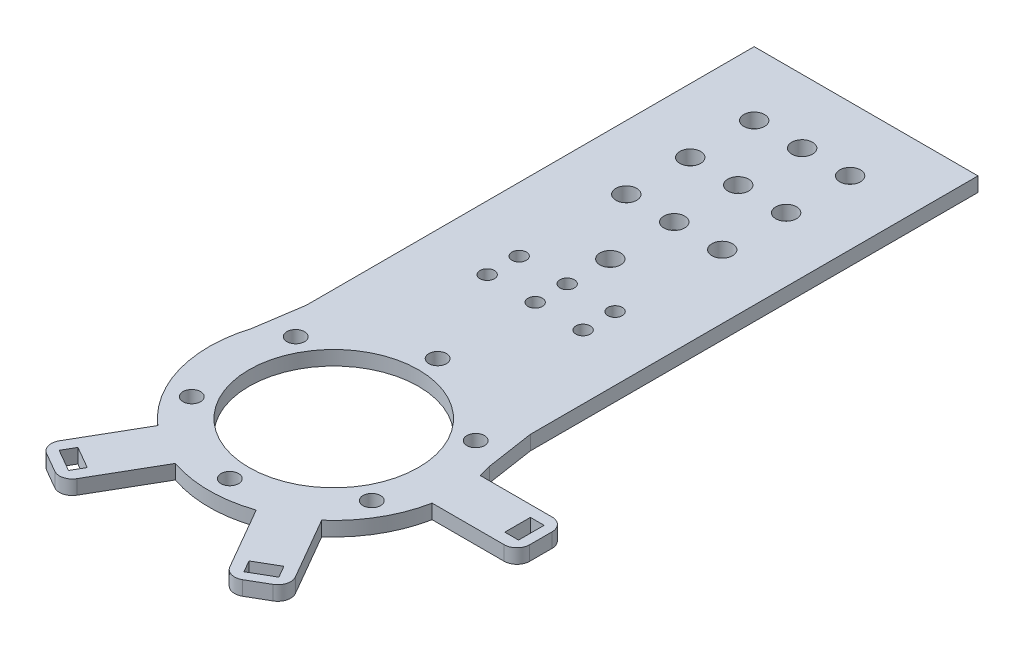
from build123d import *

# Parameters (mm, degrees)
SKETCH1_R                = 39
SKETCH1_R_2              = 26.5
BOSS_EXTRUDE1_DEPTH      = 2.25
SKETCH3_W                = 50
SKETCH3_H                = 51.5
BOSS_EXTRUDE2_DEPTH      = 2.25
BOSS_EXTRUDE4_DEPTH      = 2.25
SKETCH2_R                = 2.75
CUT_EXTRUDE1_DEPTH       = 3.25
CIRPATTERN1_COUNT        = 6
CUT_EXTRUDE2_START       = -5.5
SKETCH5_R                = 2.25
CUT_EXTRUDE2_DEPTH       = 6.5
LPATTERN1_COUNT          = 2
LPATTERN1_PITCH          = 15
LPATTERN1_COUNT_DIR2     = 2
LPATTERN1_PITCH_DIR2     = 10
LPATTERN2_COUNT          = 2
LPATTERN2_PITCH          = 15
LPATTERN2_COUNT_DIR2     = 2
LPATTERN2_PITCH_DIR2     = 10
CUT_EXTRUDE3_START       = -5.5
SKETCH7_R                = 3.25
CUT_EXTRUDE3_DEPTH       = 6.5
LPATTERN3_COUNT          = 3
LPATTERN3_PITCH          = 20
SKETCH8_R                = 3.25
CUT_EXTRUDE4_DEPTH       = 10
LPATTERN4_COUNT          = 4
LPATTERN4_PITCH          = 20
SKETCH9_W                = 27
SKETCH9_H                = 15
SKETCH9_W_2              = 4.3
SKETCH9_H_2              = 8
BOSS_EXTRUDE5_DEPTH      = 2.25
FILLET1_R                = 4
CIRPATTERN2_COUNT        = 3
CIRPATTERN2_ANGLE        = 120
FILLET1_OF_CIRPATTERN2_R = 4


with BuildPart() as part:
    # Sketch1 → Boss-Extrude1 (new body, symmetric)
    with BuildSketch(Plane(origin=(0, 0, 0), x_dir=(1, 0, 0), z_dir=(0, 1, 0))):
        Circle(SKETCH1_R)
        Circle(SKETCH1_R_2, mode=Mode.SUBTRACT)
    extrude(amount=BOSS_EXTRUDE1_DEPTH, both=True)

    # Sketch3 → Boss-Extrude2 (add, symmetric)
    with BuildSketch(Plane(origin=(0, 0, 0), x_dir=(1, 0, 0), z_dir=(0, 1, 0))):
        with Locations((0, 52.25)):
            Rectangle(SKETCH3_W, SKETCH3_H)
    extrude(amount=BOSS_EXTRUDE2_DEPTH, both=True)

    # Sketch6 → Boss-Extrude4 (add, symmetric)
    with BuildSketch(Plane(origin=(0, 0, 0), x_dir=(1, 0, 0), z_dir=(0, 1, 0))):
        Polygon((-35, 166.5), (-35, 26.5), (-39, 0), (-14.981514186, 26.5), (16.520833333, 26.5), (39, 0), (35, 26.5), (35, 166.5), align=None)
    extrude(amount=BOSS_EXTRUDE4_DEPTH, both=True)

    # Sketch2 → Cut-Extrude1 (cut, symmetric)
    with BuildSketch(Plane(origin=(0, 0, 0), x_dir=(1, 0, 0), z_dir=(0, 1, 0))):
        with Locations((0, 32.5)):
            Circle(SKETCH2_R)
    cut_extrude1 = extrude(amount=CUT_EXTRUDE1_DEPTH, both=True, mode=Mode.SUBTRACT)

    # CirPattern1: Cut-Extrude1 ×6 about axis
    cirpattern1_axis = Axis((0, 0, 0), (0, 1, 0))
    for i in range(1, CIRPATTERN1_COUNT):
        add(cut_extrude1.rotate(cirpattern1_axis, i * 360 / CIRPATTERN1_COUNT), mode=Mode.SUBTRACT)

    # Sketch5 → Cut-Extrude2 (cut)
    with BuildSketch(Plane(origin=(0, 2.25, 0), x_dir=(1, 0, 0), z_dir=(0, 1, 0)).offset(CUT_EXTRUDE2_START)):
        with Locations((0, 73)):
            Circle(SKETCH5_R)
    cut_extrude2 = extrude(amount=CUT_EXTRUDE2_DEPTH, mode=Mode.SUBTRACT)

    # LPattern1: Cut-Extrude2 2 × 2
    with Locations(*[(i * LPATTERN1_PITCH, 0, j * LPATTERN1_PITCH_DIR2) for i in range(LPATTERN1_COUNT) for j in range(LPATTERN1_COUNT_DIR2) if (i, j) != (0, 0)]):
        add(cut_extrude2, mode=Mode.SUBTRACT)

    # LPattern2: Cut-Extrude2 2 × 2
    with Locations(*[(-i * LPATTERN2_PITCH, 0, j * LPATTERN2_PITCH_DIR2) for i in range(LPATTERN2_COUNT) for j in range(LPATTERN2_COUNT_DIR2) if (i, j) != (0, 0)]):
        add(cut_extrude2, mode=Mode.SUBTRACT)

    # Sketch7 → Cut-Extrude3 (cut)
    with BuildSketch(Plane(origin=(0, 2.25, 0), x_dir=(1, 0, 0), z_dir=(0, 1, 0)).offset(CUT_EXTRUDE3_START)):
        with Locations((-15, 146.5)):
            Circle(SKETCH7_R)
        with Locations((15, 146.5)):
            Circle(SKETCH7_R)
    cut_extrude3 = extrude(amount=CUT_EXTRUDE3_DEPTH, mode=Mode.SUBTRACT)

    # LPattern3: Cut-Extrude3 ×3
    with Locations(*[(0, 0, i * LPATTERN3_PITCH) for i in range(1, LPATTERN3_COUNT)]):
        add(cut_extrude3, mode=Mode.SUBTRACT)

    # Sketch8 → Cut-Extrude4 (cut)
    with BuildSketch(Plane(origin=(0, 2.25, 0), x_dir=(1, 0, 0), z_dir=(0, 1, 0))):
        with Locations((0, 146.5)):
            Circle(SKETCH8_R)
    cut_extrude4 = extrude(amount=-CUT_EXTRUDE4_DEPTH, mode=Mode.SUBTRACT)

    # LPattern4: Cut-Extrude4 ×4
    with Locations(*[(0, 0, i * LPATTERN4_PITCH) for i in range(1, LPATTERN4_COUNT)]):
        add(cut_extrude4, mode=Mode.SUBTRACT)

    # Sketch9 → Boss-Extrude5 (add, symmetric)
    with BuildSketch(Plane(origin=(0, 0, 0), x_dir=(1, 0, 0), z_dir=(0, 1, 0))):
        with Locations((51.3, 0)):
            Rectangle(SKETCH9_W, SKETCH9_H)
        with Locations((59.65, 0)):
            Rectangle(SKETCH9_W_2, SKETCH9_H_2, mode=Mode.SUBTRACT)
    boss_extrude5 = extrude(amount=BOSS_EXTRUDE5_DEPTH, both=True)

    # Fillet1
    fillet1_edges = [part.edges().sort_by_distance(p)[0] for p in [
        (64.8, 0, 7.5),
        (64.8, 0, -7.5),
    ]]
    fillet(fillet1_edges, radius=FILLET1_R)

    # CirPattern2: Boss-Extrude5 ×3 about axis
    cirpattern2_axis = Axis((0, 0, 0), (0, -1, 0))
    for i in range(1, CIRPATTERN2_COUNT):
        add(boss_extrude5.rotate(cirpattern2_axis, i * CIRPATTERN2_ANGLE / (CIRPATTERN2_COUNT - 1)))

    # Fillet1 of CirPattern2
    fillet1_of_cirpattern2_edges = [part.edges().sort_by_distance(p)[0] for p in [
        (25.904809472, 0, 59.868446165),
        (38.895190528, 0, 52.368446165),
        (-38.895190528, 0, 52.368446165),
        (-25.904809472, 0, 59.868446165),
    ]]
    fillet(fillet1_of_cirpattern2_edges, radius=FILLET1_OF_CIRPATTERN2_R)


solid = part.part
